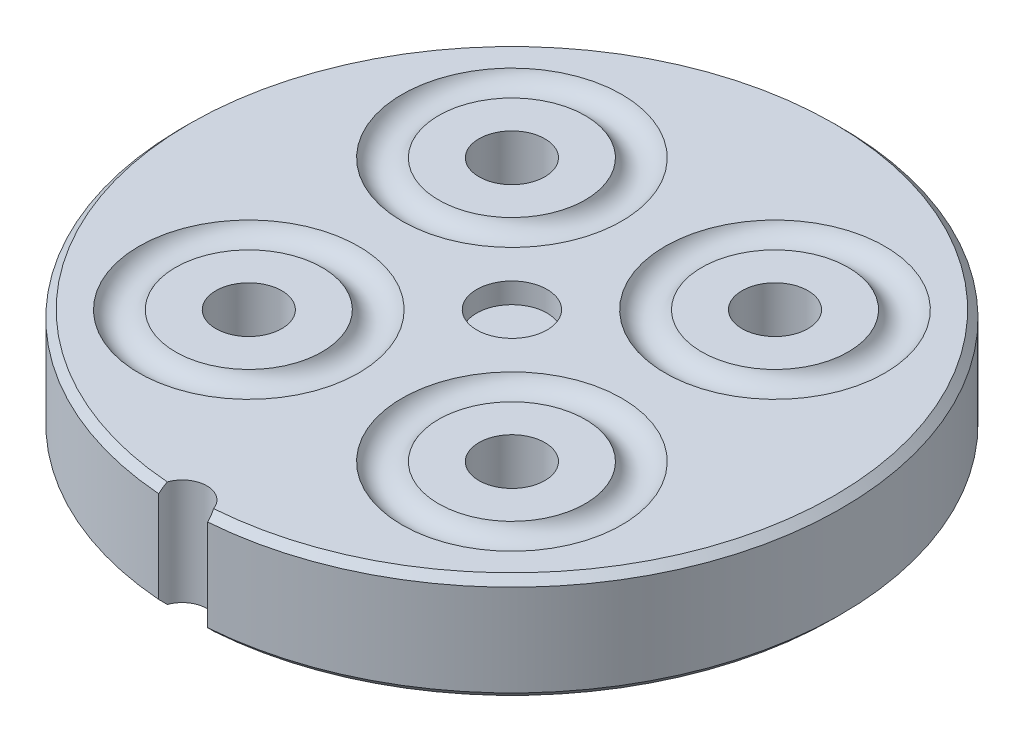
from build123d import *

# Parameters (mm, degrees)
EXTRUDE1_DEPTH    = 7.25
CHAMFER1_SIZE     = 0.5
SKETCH2_R         = 2.25
EXTRUDE2_DEPTH    = 10
CIRPATTERN1_COUNT = 4
SKETCH4_R         = 2.4
EXTRUDE3_DEPTH    = 1.4


with BuildPart() as part:
    # Sketch1 → Extrude1 (new body)
    with BuildSketch(Plane(origin=(0, 0, 0), x_dir=(1, 0, 0), z_dir=(0, 1, 0))):
        with BuildLine():
            ThreePointArc((1.673839247, -22.437652778), (0, 22.5), (-1.673839247, -22.437652778))
            ThreePointArc((-1.673839247, -22.437652778), (0, -20.825), (1.673839247, -22.437652778))
        make_face()
    extrude(amount=EXTRUDE1_DEPTH)

    # Chamfer1
    chamfer1_edges = [part.edges().sort_by_distance(p)[0] for p in [
        (0, 0, -22.5),
        (0, 7.25, -22.5),
    ]]
    chamfer(chamfer1_edges, length=CHAMFER1_SIZE)

    # Sketch2 → Extrude2 (cut)
    with BuildSketch(Plane(origin=(0, 0, 0), x_dir=(1, 0, 0), z_dir=(0, 1, 0))):
        with Locations((-8.980256121, 8.980256121)):
            Circle(SKETCH2_R)
        with Locations((8.980256121, 8.980256121)):
            Circle(SKETCH2_R)
        with Locations((8.980256121, -8.980256121)):
            Circle(SKETCH2_R)
        with Locations((-8.980256121, -8.980256121)):
            Circle(SKETCH2_R)
    extrude(amount=EXTRUDE2_DEPTH, mode=Mode.SUBTRACT)

    # Sketch3 → Cut-Revolve1 (revolve, cut)
    with BuildSketch(Plane(origin=(0, 0, 0), x_dir=(-0.7071067811865513, 0, 0.7071067811865438), z_dir=(-0.7071067811865438, 0, -0.7071067811865513))):
        with BuildLine():
            Line((5.2, 7.25), (7.7, 7.25))
            ThreePointArc((7.7, 7.25), (6.45, 6.434349972), (5.2, 7.25))
        make_face()
        with BuildLine():
            Line((5.2, 0), (7.707571991, 0))
            ThreePointArc((7.707571991, 0), (6.453785996, 0.824336185), (5.2, 0))
        make_face()
    cut_revolve1 = revolve(axis=Axis((-8.980256121, 11.072840969, 8.980256121), (0, -1, 0)), mode=Mode.SUBTRACT)

    # CirPattern1: Cut-Revolve1 ×4 about axis
    cirpattern1_axis = Axis((0, 7.6125, 0), (0, -1, 0))
    for i in range(1, CIRPATTERN1_COUNT):
        add(cut_revolve1.rotate(cirpattern1_axis, i * 360 / CIRPATTERN1_COUNT), mode=Mode.SUBTRACT)

    # Sketch4 → Extrude3 (cut)
    with BuildSketch(Plane(origin=(0, 7.25, 0), x_dir=(1, 0, 0), z_dir=(0, 1, 0))):
        Circle(SKETCH4_R)
    extrude(amount=-EXTRUDE3_DEPTH, mode=Mode.SUBTRACT)


solid = part.part
